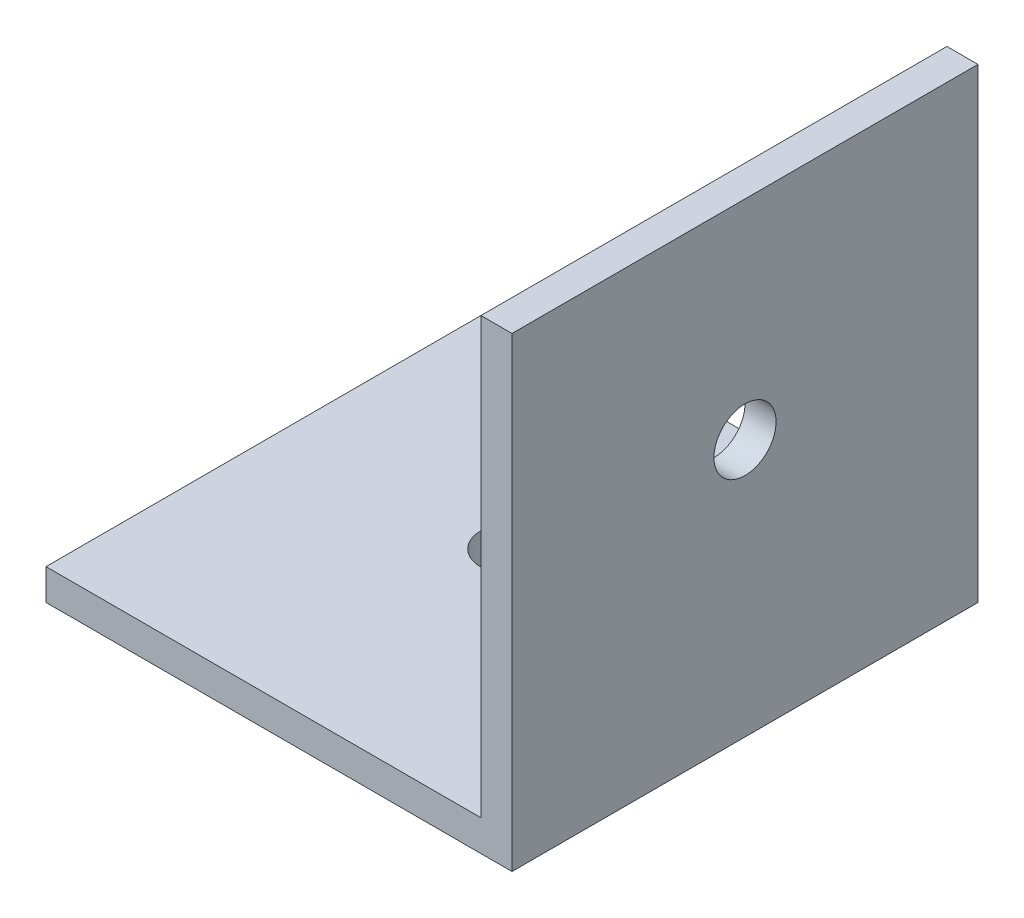
from build123d import *

# Parameters (mm, degrees)
EXTRUDE_1_DEPTH     = 15
SKETCH_2_R          = 1
CUT_EXTRUDE_1_DEPTH = 2
SKETCH_3_R          = 1
CUT_EXTRUDE_2_DEPTH = 2


with BuildPart() as part:
    # 草图1 → 凸台-拉伸1 (new body)
    with BuildSketch(Plane.XY):
        Polygon((0, 0), (-15, 0), (-15, 1), (-1, 1), (-1, 15), (0, 15), align=None)
    extrude(amount=EXTRUDE_1_DEPTH)

    # 草图2 → 切除-拉伸1 (cut, through all)
    with BuildSketch(Plane.ZY.offset(1)):
        with Locations((7.5, 8.288332676)):
            Circle(SKETCH_2_R)
    extrude(amount=-CUT_EXTRUDE_1_DEPTH, mode=Mode.SUBTRACT)

    # 草图3 → 切除-拉伸2 (cut, through all)
    with BuildSketch(Plane(origin=(0, 1, 0), x_dir=(1, 0, 0), z_dir=(0, 1, 0))):
        with Locations((-8, -7.011984534)):
            Circle(SKETCH_3_R)
    extrude(amount=-CUT_EXTRUDE_2_DEPTH, mode=Mode.SUBTRACT)


solid = part.part
